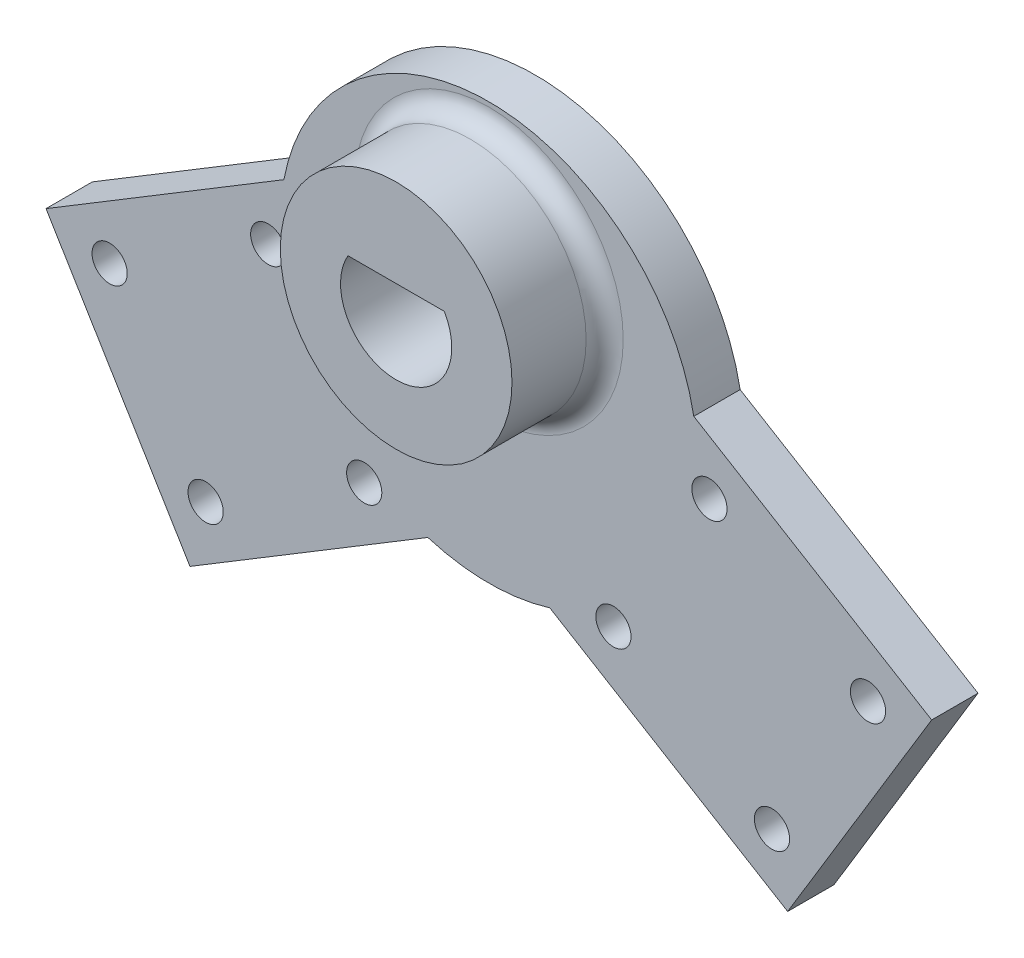
from build123d import *

# Parameters (mm, degrees)
BOSS_EXTRUDE1_DEPTH  = 5
M3_CLEARANCE_HOLE1_D = 3.8
BOSS_EXTRUDE3_START  = 5
SKETCH2_6_R          = 12.5
BOSS_EXTRUDE3_DEPTH  = 10
FILLET1_R            = 2


with BuildPart() as part:
    # Sketch2 → Boss-Extrude1 (new body)
    with BuildSketch(Plane.XY):
        with BuildLine():
            Line((6.578363356, -21.516857009), (32.24208854, -37.05304733))
            Line((32.24208854, -37.05304733), (47.778278861, -11.389322146))
            Line((47.778278861, -11.389322146), (22.114553677, 4.146868175))
            ThreePointArc((22.114553677, 4.146868175), (0, 22.5), (-22.114553677, 4.146868175))
            Line((-22.114553677, 4.146868175), (-47.778278861, -11.389322146))
            Line((-47.778278861, -11.389322146), (-32.24208854, -37.05304733))
            Line((-32.24208854, -37.05304733), (-6.578363356, -21.516857009))
            ThreePointArc((-6.578363356, -21.516857009), (0, -22.5), (6.578363356, -21.516857009))
        make_face()
        with BuildLine():
            Line((5.196152423, 10.5), (-5.196152423, 10.5))
            ThreePointArc((-5.196152423, 10.5), (0, 1.5), (5.196152423, 10.5))
        make_face(mode=Mode.SUBTRACT)
    extrude(amount=BOSS_EXTRUDE1_DEPTH)

    # M3 Clearance Hole1 (through all)
    with Locations(Plane.XY.offset(5)):
        with Locations((-40.911626277, -13.077244623), (-23.802476154, -2.719784409), (-13.44501594, -19.828934532), (-30.554166063, -30.186394746), (13.44501594, -19.828934532), (23.802476154, -2.719784409), (40.911626277, -13.077244623), (30.554166063, -30.186394746)):
            Hole(M3_CLEARANCE_HOLE1_D / 2)

    # Sketch2_6 → Boss-Extrude3 (add)
    with BuildSketch(Plane.XY.offset(BOSS_EXTRUDE3_START)):
        with Locations((0, 7.5)):
            Circle(SKETCH2_6_R)
        with BuildLine():
            ThreePointArc((-5.196152423, 10.5), (0, 1.5), (5.196152423, 10.5))
            Line((5.196152423, 10.5), (-5.196152423, 10.5))
        make_face(mode=Mode.SUBTRACT)
    extrude(amount=BOSS_EXTRUDE3_DEPTH)

    # Fillet1
    fillet1_edges = [part.edges().sort_by_distance(p)[0] for p in [
        (-12.5, 7.5, 5),
    ]]
    fillet(fillet1_edges, radius=FILLET1_R)


solid = part.part
